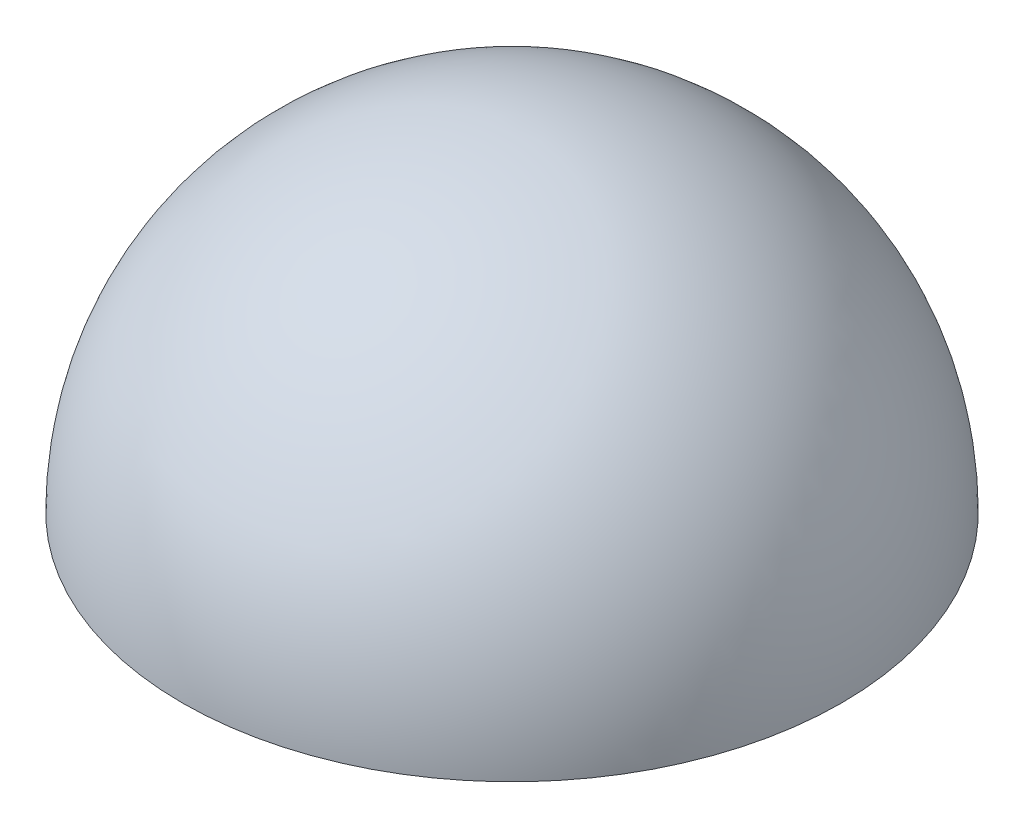
from build123d import *


with BuildPart() as part:
    # Sketch1 → Revolve1 (revolve)
    with BuildSketch(Plane.XY):
        with BuildLine():
            Line((0, 2), (3, 2))
            ThreePointArc((3, 2), (2.121320344, 4.121320344), (0, 5))
            Line((0, 5), (0, 2))
        make_face()
    revolve(axis=Axis((0, 2, 0), (0, 1, 0)))


solid = part.part
